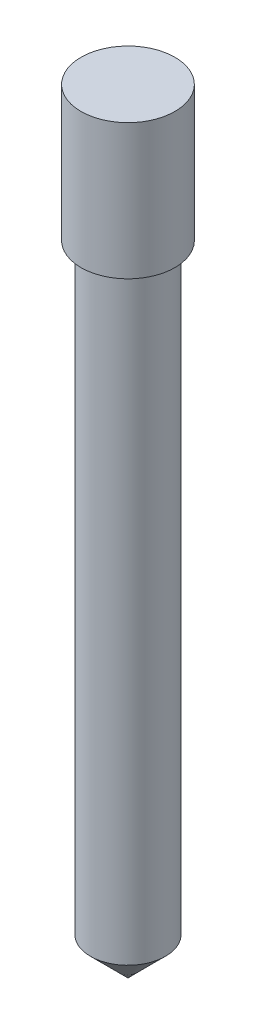
from build123d import *

# Parameters (mm, degrees)
SKETCH1_R           = 5
BOSS_EXTRUDE1_DEPTH = 85
CHAMFER1_SIZE       = 5
SKETCH2_R           = 6.25
BOSS_EXTRUDE2_DEPTH = 18


with BuildPart() as part:
    # Sketch1 → Boss-Extrude1 (new body)
    with BuildSketch(Plane(origin=(0, 0, 0), x_dir=(1, 0, 0), z_dir=(0, 1, 0))):
        Circle(SKETCH1_R)
    extrude(amount=BOSS_EXTRUDE1_DEPTH)

    # Chamfer1
    chamfer1_edges = [part.edges().sort_by_distance(p)[0] for p in [
        (-5, 0, 0),
    ]]
    chamfer(chamfer1_edges, length=CHAMFER1_SIZE)

    # Sketch2 → Boss-Extrude2 (add)
    with BuildSketch(Plane(origin=(0, 85, 0), x_dir=(1, 0, 0), z_dir=(0, 1, 0))):
        Circle(SKETCH2_R)
    extrude(amount=BOSS_EXTRUDE2_DEPTH)


solid = part.part
